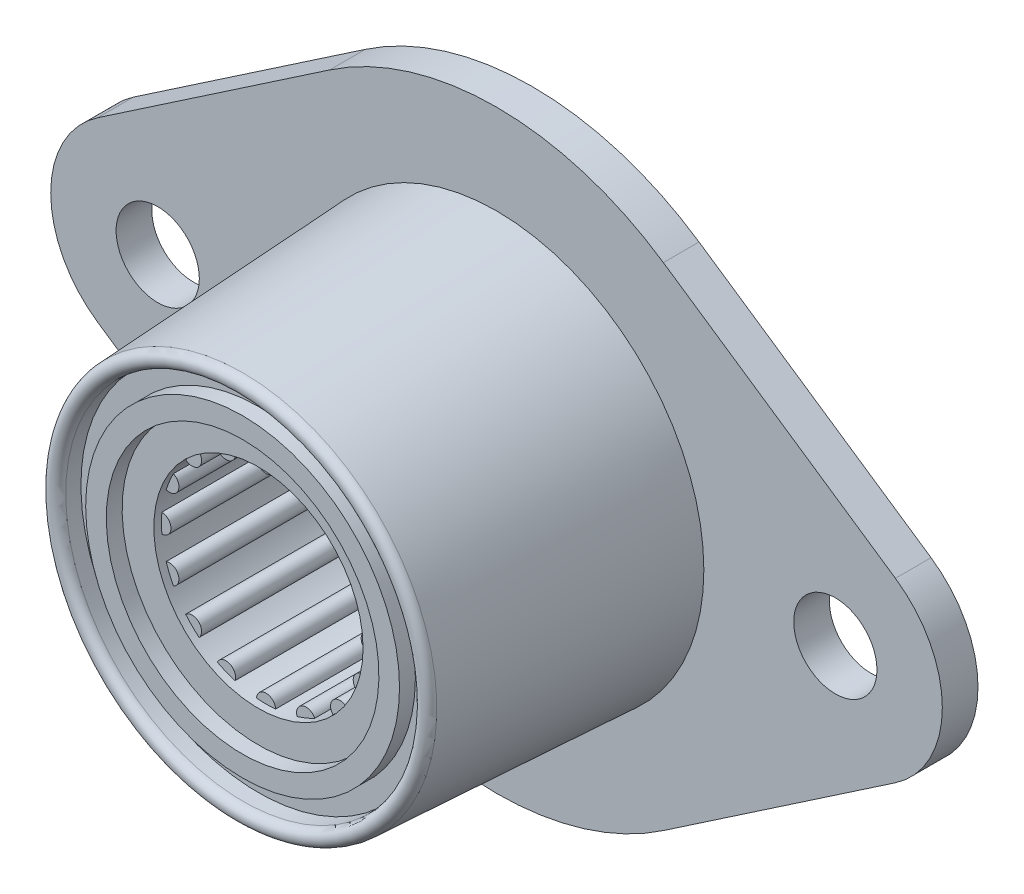
from build123d import *

# Parameters (mm, degrees)
SKETCH1_R          = 2.778125
SKETCH1_R_2        = 13.843
EXTRUDE1_DEPTH     = 2.38125
CUT_EXTRUDE2_DEPTH = 19.276949285
SKETCH4_R          = 6.985
CUT_EXTRUDE3_DEPTH = 0.508
SKETCH5_R          = 6.985
CUT_EXTRUDE4_DEPTH = 0.508


with BuildPart() as part:
    # Sketch1 → Extrude1 (new body)
    with BuildSketch(Plane.XY):
        with BuildLine():
            Line((-26.632401316, 5.911754624), (-11.140350877, 16.421540622))
            ThreePointArc((-11.140350877, 16.421540622), (0, 19.84375), (11.140350877, 16.421540622))
            Line((11.140350877, 16.421540622), (26.632401316, 5.911754624))
            ThreePointArc((26.632401316, 5.911754624), (29.765625, 0), (26.632401316, -5.911754624))
            Line((26.632401316, -5.911754624), (11.140350877, -16.421540622))
            ThreePointArc((11.140350877, -16.421540622), (0, -19.84375), (-11.140350877, -16.421540622))
            Line((-11.140350877, -16.421540622), (-26.632401316, -5.911754624))
            ThreePointArc((-26.632401316, -5.911754624), (-29.765625, 0), (-26.632401316, 5.911754624))
        make_face()
        with Locations((-22.621875, 0)):
            Circle(SKETCH1_R, mode=Mode.SUBTRACT)
        with Locations((22.621875, 0)):
            Circle(SKETCH1_R, mode=Mode.SUBTRACT)
        Circle(SKETCH1_R_2, mode=Mode.SUBTRACT)
    extrude(amount=EXTRUDE1_DEPTH)

    # Sketch2 → Revolve1 (revolve)
    with BuildSketch(Plane(origin=(0, 0, 0), x_dir=(0, 0, -1), z_dir=(1, 0, 0))):
        with BuildLine():
            Line((0, 13.843), (-2.38125, 13.843))
            Line((-2.38125, 13.843), (-19.321775967, 12.955184654))
            ThreePointArc((-19.321775967, 12.955184654), (-19.692486007, 12.784284985), (-19.84375, 12.405138793))
            ThreePointArc((-19.84375, 12.405138793), (-19.682424206, 12.015663872), (-19.292949285, 11.854338078))
            Line((-19.292949285, 11.854338078), (-18.276949285, 11.854338078))
            Line((-18.276949285, 11.854338078), (-18.276949285, 10.478253558))
            Line((-18.276949285, 10.478253558), (-19.33575, 10.478253558))
            Line((-19.33575, 10.478253558), (-19.33575, 9.102169039))
            Line((-19.33575, 9.102169039), (-18.276949285, 9.102169039))
            Line((-18.276949285, 9.102169039), (-18.276949285, 7.726084519))
            Line((-18.276949285, 7.726084519), (-18.276949285, 6.35))
            Line((-18.276949285, 6.35), (0, 6.35))
            Line((0, 6.35), (0, 13.843))
        make_face()
    revolve(axis=Axis((0, 0, 0), (0, 0, 1)))

    # Sketch3 → Cut-Extrude2 (cut, through all)
    with BuildSketch(Plane.XY.offset(18.276949285)):
        with BuildLine():
            ThreePointArc((-3.248055272, 6.183879199), (-3.880658078, 5.807815242), (-4.470182484, 5.367279904))
            ThreePointArc((-4.470182484, 5.367279904), (-4.490128061, 4.490128061), (-5.367279904, 4.470182484))
            ThreePointArc((-5.367279904, 4.470182484), (-5.807815242, 3.880658078), (-6.183879199, 3.248055272))
            ThreePointArc((-6.183879199, 3.248055272), (-5.866635031, 2.430039796), (-6.669384824, 2.075941007))
            ThreePointArc((-6.669384824, 2.075941007), (-6.850785184, 1.362705899), (-6.956136364, 0.634343669))
            ThreePointArc((-6.956136364, 0.634343669), (-6.35, 0), (-6.956136364, -0.634343669))
            ThreePointArc((-6.956136364, -0.634343669), (-6.850785184, -1.362705899), (-6.669384824, -2.075941007))
            ThreePointArc((-6.669384824, -2.075941007), (-5.866635031, -2.430039796), (-6.183879199, -3.248055272))
            ThreePointArc((-6.183879199, -3.248055272), (-5.807815242, -3.880658078), (-5.367279904, -4.470182484))
            ThreePointArc((-5.367279904, -4.470182484), (-4.490128061, -4.490128061), (-4.470182484, -5.367279904))
            ThreePointArc((-4.470182484, -5.367279904), (-3.880658078, -5.807815242), (-3.248055272, -6.183879199))
            ThreePointArc((-3.248055272, -6.183879199), (-2.430039796, -5.866635031), (-2.075941007, -6.669384824))
            ThreePointArc((-2.075941007, -6.669384824), (-1.362705899, -6.850785184), (-0.634343669, -6.956136364))
            ThreePointArc((-0.634343669, -6.956136364), (0, -6.35), (0.634343669, -6.956136364))
            ThreePointArc((0.634343669, -6.956136364), (1.362705899, -6.850785184), (2.075941007, -6.669384824))
            ThreePointArc((2.075941007, -6.669384824), (2.430039796, -5.866635031), (3.248055272, -6.183879199))
            ThreePointArc((3.248055272, -6.183879199), (3.880658078, -5.807815242), (4.470182484, -5.367279904))
            ThreePointArc((4.470182484, -5.367279904), (4.490128061, -4.490128061), (5.367279904, -4.470182484))
            ThreePointArc((5.367279904, -4.470182484), (5.807815242, -3.880658078), (6.183879199, -3.248055272))
            ThreePointArc((6.183879199, -3.248055272), (5.866635031, -2.430039796), (6.669384824, -2.075941007))
            ThreePointArc((6.669384824, -2.075941007), (6.850785184, -1.362705899), (6.956136364, -0.634343669))
            ThreePointArc((6.956136364, -0.634343669), (6.35, 0), (6.956136364, 0.634343669))
            ThreePointArc((6.956136364, 0.634343669), (6.850785184, 1.362705899), (6.669384824, 2.075941007))
            ThreePointArc((6.669384824, 2.075941007), (5.866635031, 2.430039796), (6.183879199, 3.248055272))
            ThreePointArc((6.183879199, 3.248055272), (5.807815242, 3.880658078), (5.367279904, 4.470182484))
            ThreePointArc((5.367279904, 4.470182484), (4.490128061, 4.490128061), (4.470182484, 5.367279904))
            ThreePointArc((4.470182484, 5.367279904), (3.880658078, 5.807815242), (3.248055272, 6.183879199))
            ThreePointArc((3.248055272, 6.183879199), (2.430039796, 5.866635031), (2.075941007, 6.669384824))
            ThreePointArc((2.075941007, 6.669384824), (1.362705899, 6.850785184), (0.634343669, 6.956136364))
            ThreePointArc((0.634343669, 6.956136364), (0, 6.35), (-0.634343669, 6.956136364))
            ThreePointArc((-0.634343669, 6.956136364), (-1.362705899, 6.850785184), (-2.075941007, 6.669384824))
            ThreePointArc((-2.075941007, 6.669384824), (-2.430039796, 5.866635031), (-3.248055272, 6.183879199))
        make_face()
    extrude(amount=-CUT_EXTRUDE2_DEPTH, mode=Mode.SUBTRACT)

    # Sketch4 → Cut-Extrude3 (cut)
    with BuildSketch(Plane.XY.offset(18.276949285)):
        Circle(SKETCH4_R)
    extrude(amount=-CUT_EXTRUDE3_DEPTH, mode=Mode.SUBTRACT)

    # Sketch5 → Cut-Extrude4 (cut)
    with BuildSketch(Plane(origin=(0, 0, 0), x_dir=(-1, 0, 0), z_dir=(0, 0, -1))):
        Circle(SKETCH5_R)
    extrude(amount=-CUT_EXTRUDE4_DEPTH, mode=Mode.SUBTRACT)


solid = part.part
